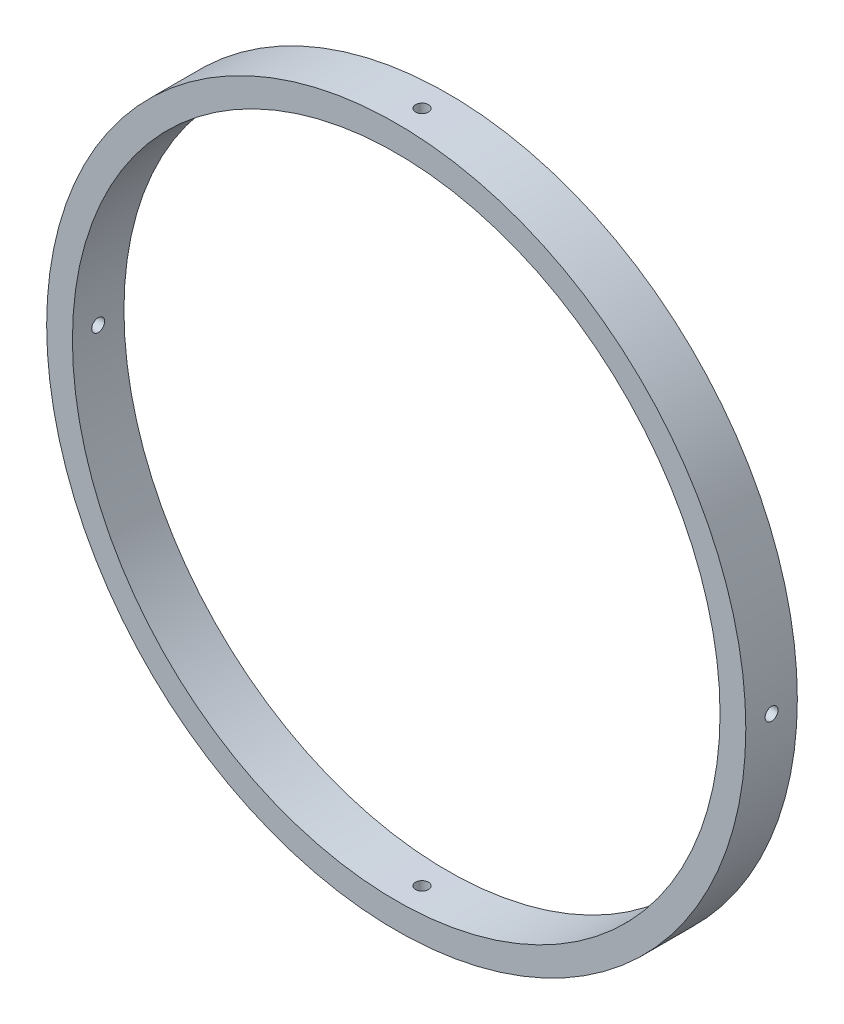
from build123d import *

# Parameters (mm, degrees)
SKETCH3_R           = 43.0784
SKETCH3_R_2         = 39.9034
BOSS_EXTRUDE1_DEPTH = 3.175
SKETCH4_R           = 0.79375
CUT_EXTRUDE1_DEPTH  = 62.004735211
CIRPATTERN1_COUNT   = 4


with BuildPart() as part:
    # Sketch3 → Boss-Extrude1 (new, symmetric)
    with BuildSketch(Plane.XY):
        Circle(SKETCH3_R)
        Circle(SKETCH3_R_2, mode=Mode.SUBTRACT)
    extrude(amount=BOSS_EXTRUDE1_DEPTH, both=True)

    # Sketch4 → Cut-Extrude1 (cut, through all)
    with BuildSketch(Plane(origin=(0, 0, 0), x_dir=(1, 0, 0), z_dir=(0, 1, 0))):
        with Locations(Location((0, 0, 0), (0, 0, 270))):
            Circle(SKETCH4_R)
    cut_extrude1 = extrude(amount=-CUT_EXTRUDE1_DEPTH, mode=Mode.SUBTRACT)

    # CirPattern1: Cut-Extrude1 ×4 about axis
    cirpattern1_axis = Axis((0, 0, 3.175), (0, 0, -1))
    for i in range(1, CIRPATTERN1_COUNT):
        add(cut_extrude1.rotate(cirpattern1_axis, i * 360 / CIRPATTERN1_COUNT), mode=Mode.SUBTRACT)


solid = part.part
